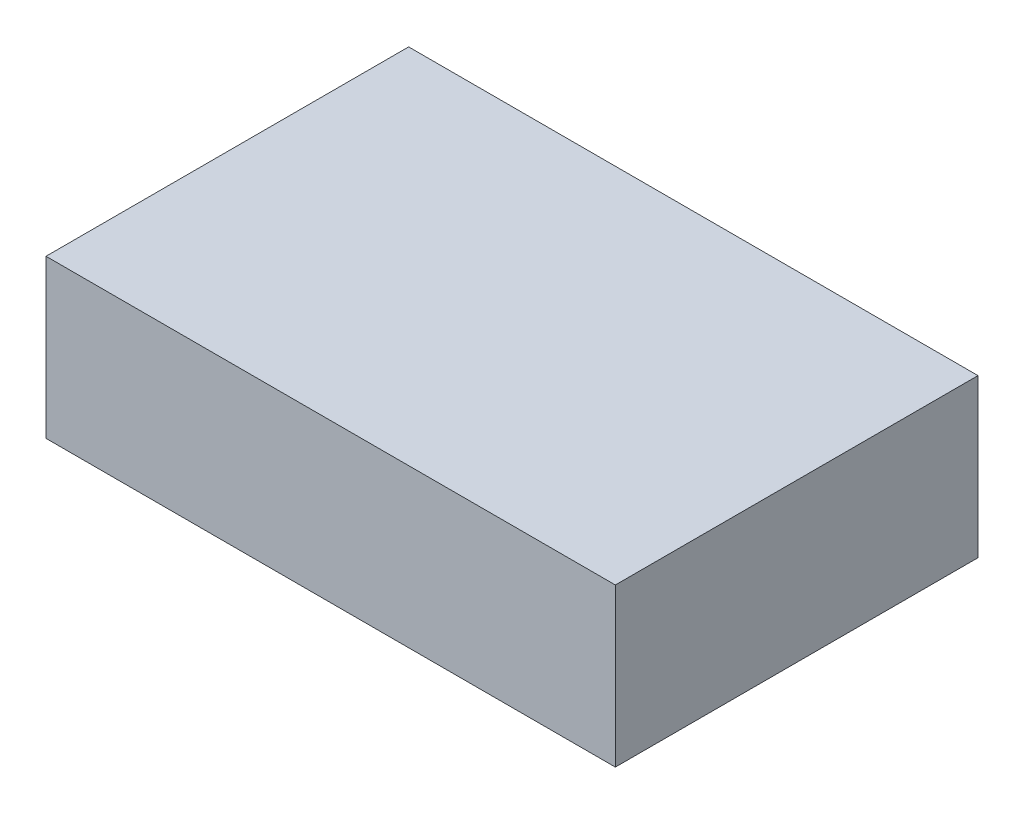
from build123d import *

# Parameters (mm, degrees)
SKETCH1_W           = 314
SKETCH1_H           = 200
BOSS_EXTRUDE1_DEPTH = 87


with BuildPart() as part:
    # Sketch1 → Boss-Extrude1 (new body)
    with BuildSketch(Plane(origin=(0, 0, 0), x_dir=(1, 0, 0), z_dir=(0, 1, 0))):
        with Locations((157, 100)):
            Rectangle(SKETCH1_W, SKETCH1_H)
    extrude(amount=BOSS_EXTRUDE1_DEPTH)


solid = part.part
